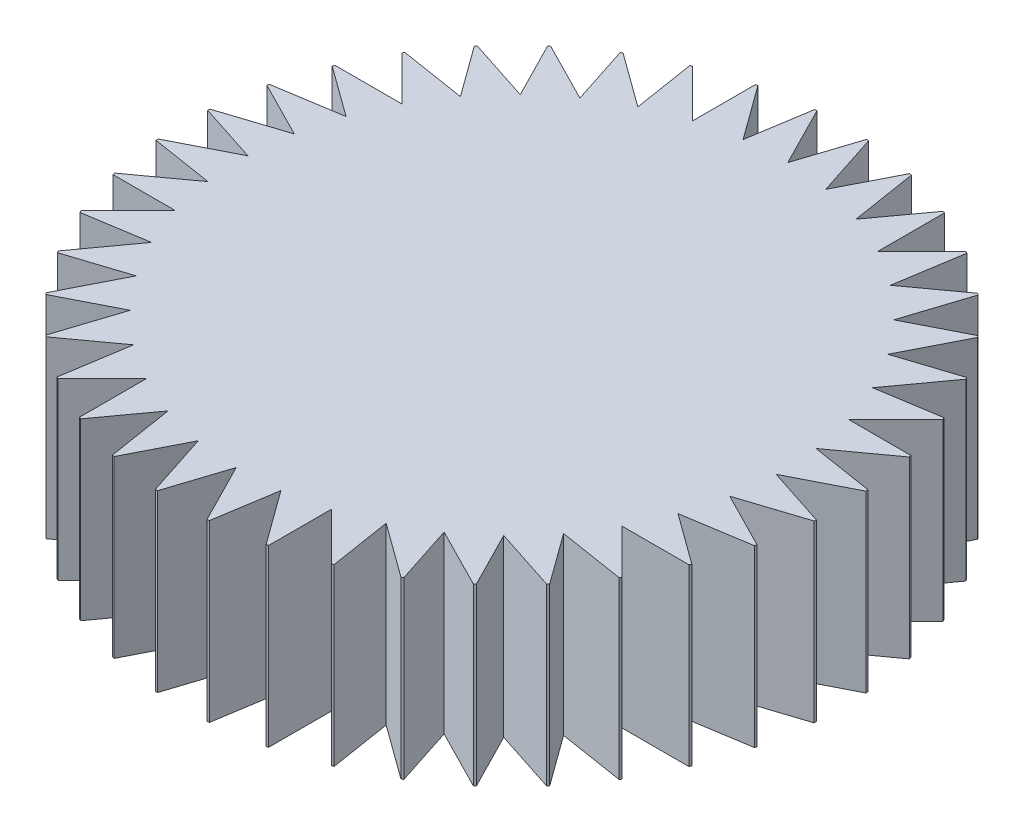
from build123d import *

# Parameters (mm, degrees)
Y_KSEKLIK_EKSTR_ZYON1_DEPTH = 3


with BuildPart() as part:
    # Çizim1 → Yükseklik-Ekstrüzyon1 (new body)
    with BuildSketch(Plane(origin=(0, 0, 0), x_dir=(1, 0, 0), z_dir=(0, 1, 0))):
        with BuildLine():
            Line((-1.336008246, 4.436405178), (-2.146846221, 5.247243153))
            ThreePointArc((-2.146846221, 5.247243153), (-2.164173955, 5.240120274), (-2.181478058, 5.232940176))
            Line((-2.181478058, 5.232940176), (-2.013566438, 4.172787933))
            Line((-2.013566438, 4.172787933), (-2.941264657, 4.846800142))
            ThreePointArc((-2.941264657, 4.846800142), (-2.957264794, 4.837054303), (-2.97323264, 4.827255646))
            Line((-2.97323264, 4.827255646), (-2.641543942, 3.806422801))
            Line((-2.641543942, 3.806422801), (-3.663259395, 4.327012826))
            ThreePointArc((-3.663259395, 4.327012826), (-3.67753796, 4.314884002), (-3.691776367, 4.302708061))
            Line((-3.691776367, 4.302708061), (-3.204477867, 3.346330906))
            Line((-3.204477867, 3.346330906), (-4.29505253, 3.700680094))
            ThreePointArc((-4.29505253, 3.700680094), (-4.307257936, 3.686466936), (-4.319416307, 3.672213524))
            Line((-4.319416307, 3.672213524), (-3.688506912, 2.803841239))
            Line((-3.688506912, 2.803841239), (-4.821087217, 2.983224337))
            ThreePointArc((-4.821087217, 2.983224337), (-4.830918926, 2.96727682), (-4.840697883, 2.951296902))
            Line((-4.840697883, 2.951296902), (-4.081712675, 2.192311695))
            Line((-4.081712675, 2.192311695), (-5.228410736, 2.192311695))
            ThreePointArc((-5.228410736, 2.192311695), (-5.23562666, 2.175022501), (-5.242785411, 2.157709556))
            Line((-5.242785411, 2.157709556), (-4.374413126, 1.526800161))
            Line((-4.374413126, 1.526800161), (-5.506993431, 1.347417063))
            ThreePointArc((-5.506993431, 1.347417063), (-5.511415889, 1.329211909), (-5.515778163, 1.31099224))
            Line((-5.515778163, 1.31099224), (-4.559401008, 0.82369374))
            Line((-4.559401008, 0.82369374), (-5.649975671, 0.469344552))
            ThreePointArc((-5.649975671, 0.469344552), (-5.651495767, 0.450671709), (-5.652954151, 0.431993944))
            Line((-5.652954151, 0.431993944), (-4.632121306, 0.100305246))
            Line((-4.632121306, 0.100305246), (-5.653836759, -0.42028478))
            ThreePointArc((-5.653836759, -0.42028478), (-5.652417064, -0.438965525), (-5.650935646, -0.457641477))
            Line((-5.650935646, -0.457641477), (-4.590783403, -0.625553097))
            Line((-4.590783403, -0.625553097), (-5.518481622, -1.299565306))
            ThreePointArc((-5.518481622, -1.299565306), (-5.514157093, -1.317793971), (-5.509772351, -1.336008246))
            Line((-5.509772351, -1.336008246), (-4.436405178, -1.336008246))
            Line((-4.436405178, -1.336008246), (-5.247243153, -2.146846221))
            ThreePointArc((-5.247243153, -2.146846221), (-5.240120274, -2.164173955), (-5.232940176, -2.181478058))
            Line((-5.232940176, -2.181478058), (-4.172787933, -2.013566438))
            Line((-4.172787933, -2.013566438), (-4.846800142, -2.941264657))
            ThreePointArc((-4.846800142, -2.941264657), (-4.837054303, -2.957264794), (-4.827255646, -2.97323264))
            Line((-4.827255646, -2.97323264), (-3.806422801, -2.641543942))
            Line((-3.806422801, -2.641543942), (-4.327012826, -3.663259395))
            ThreePointArc((-4.327012826, -3.663259395), (-4.314884002, -3.67753796), (-4.302708061, -3.691776367))
            Line((-4.302708061, -3.691776367), (-3.346330906, -3.204477867))
            Line((-3.346330906, -3.204477867), (-3.700680094, -4.29505253))
            ThreePointArc((-3.700680094, -4.29505253), (-3.686466936, -4.307257936), (-3.672213524, -4.319416307))
            Line((-3.672213524, -4.319416307), (-2.803841239, -3.688506912))
            Line((-2.803841239, -3.688506912), (-2.983224337, -4.821087217))
            ThreePointArc((-2.983224337, -4.821087217), (-2.96727682, -4.830918926), (-2.951296902, -4.840697883))
            Line((-2.951296902, -4.840697883), (-2.192311695, -4.081712675))
            Line((-2.192311695, -4.081712675), (-2.192311695, -5.228410736))
            ThreePointArc((-2.192311695, -5.228410736), (-2.175022501, -5.23562666), (-2.157709556, -5.242785411))
            Line((-2.157709556, -5.242785411), (-1.526800161, -4.374413126))
            Line((-1.526800161, -4.374413126), (-1.347417063, -5.506993431))
            ThreePointArc((-1.347417063, -5.506993431), (-1.329211909, -5.511415889), (-1.31099224, -5.515778163))
            Line((-1.31099224, -5.515778163), (-0.82369374, -4.559401008))
            Line((-0.82369374, -4.559401008), (-0.469344552, -5.649975671))
            ThreePointArc((-0.469344552, -5.649975671), (-0.450671709, -5.651495767), (-0.431993944, -5.652954151))
            Line((-0.431993944, -5.652954151), (-0.100305246, -4.632121306))
            Line((-0.100305246, -4.632121306), (0.42028478, -5.653836759))
            ThreePointArc((0.42028478, -5.653836759), (0.438965525, -5.652417064), (0.457641477, -5.650935646))
            Line((0.457641477, -5.650935646), (0.625553097, -4.590783403))
            Line((0.625553097, -4.590783403), (1.299565306, -5.518481622))
            ThreePointArc((1.299565306, -5.518481622), (1.317793971, -5.514157093), (1.336008246, -5.509772351))
            Line((1.336008246, -5.509772351), (1.336008246, -4.436405178))
            Line((1.336008246, -4.436405178), (2.146846221, -5.247243153))
            ThreePointArc((2.146846221, -5.247243153), (2.164173955, -5.240120274), (2.181478058, -5.232940176))
            Line((2.181478058, -5.232940176), (2.013566438, -4.172787933))
            Line((2.013566438, -4.172787933), (2.941264657, -4.846800142))
            ThreePointArc((2.941264657, -4.846800142), (2.957264794, -4.837054303), (2.97323264, -4.827255646))
            Line((2.97323264, -4.827255646), (2.641543942, -3.806422801))
            Line((2.641543942, -3.806422801), (3.663259395, -4.327012826))
            ThreePointArc((3.663259395, -4.327012826), (3.67753796, -4.314884002), (3.691776367, -4.302708061))
            Line((3.691776367, -4.302708061), (3.204477867, -3.346330906))
            Line((3.204477867, -3.346330906), (4.29505253, -3.700680094))
            ThreePointArc((4.29505253, -3.700680094), (4.307257936, -3.686466936), (4.319416307, -3.672213524))
            Line((4.319416307, -3.672213524), (3.688506912, -2.803841239))
            Line((3.688506912, -2.803841239), (4.821087217, -2.983224337))
            ThreePointArc((4.821087217, -2.983224337), (4.830918926, -2.96727682), (4.840697883, -2.951296902))
            Line((4.840697883, -2.951296902), (4.081712675, -2.192311695))
            Line((4.081712675, -2.192311695), (5.228410736, -2.192311695))
            ThreePointArc((5.228410736, -2.192311695), (5.23562666, -2.175022501), (5.242785411, -2.157709556))
            Line((5.242785411, -2.157709556), (4.374413126, -1.526800161))
            Line((4.374413126, -1.526800161), (5.506993431, -1.347417063))
            ThreePointArc((5.506993431, -1.347417063), (5.511415889, -1.329211909), (5.515778163, -1.31099224))
            Line((5.515778163, -1.31099224), (4.559401008, -0.82369374))
            Line((4.559401008, -0.82369374), (5.649975671, -0.469344552))
            ThreePointArc((5.649975671, -0.469344552), (5.651495767, -0.450671709), (5.652954151, -0.431993944))
            Line((5.652954151, -0.431993944), (4.632121306, -0.100305246))
            Line((4.632121306, -0.100305246), (5.653836759, 0.42028478))
            ThreePointArc((5.653836759, 0.42028478), (5.652417064, 0.438965525), (5.650935646, 0.457641477))
            Line((5.650935646, 0.457641477), (4.590783403, 0.625553097))
            Line((4.590783403, 0.625553097), (5.518481622, 1.299565306))
            ThreePointArc((5.518481622, 1.299565306), (5.514157093, 1.317793971), (5.509772351, 1.336008246))
            Line((5.509772351, 1.336008246), (4.436405178, 1.336008246))
            Line((4.436405178, 1.336008246), (5.247243153, 2.146846221))
            ThreePointArc((5.247243153, 2.146846221), (5.240120274, 2.164173955), (5.232940176, 2.181478058))
            Line((5.232940176, 2.181478058), (4.172787933, 2.013566438))
            Line((4.172787933, 2.013566438), (4.846800142, 2.941264657))
            ThreePointArc((4.846800142, 2.941264657), (4.837054303, 2.957264794), (4.827255646, 2.97323264))
            Line((4.827255646, 2.97323264), (3.806422801, 2.641543942))
            Line((3.806422801, 2.641543942), (4.327012826, 3.663259395))
            ThreePointArc((4.327012826, 3.663259395), (4.314884002, 3.67753796), (4.302708061, 3.691776367))
            Line((4.302708061, 3.691776367), (3.346330906, 3.204477867))
            Line((3.346330906, 3.204477867), (3.700680094, 4.29505253))
            ThreePointArc((3.700680094, 4.29505253), (3.686466936, 4.307257936), (3.672213524, 4.319416307))
            Line((3.672213524, 4.319416307), (2.803841239, 3.688506912))
            Line((2.803841239, 3.688506912), (2.983224337, 4.821087217))
            ThreePointArc((2.983224337, 4.821087217), (2.96727682, 4.830918926), (2.951296902, 4.840697883))
            Line((2.951296902, 4.840697883), (2.192311695, 4.081712675))
            Line((2.192311695, 4.081712675), (2.192311695, 5.228410736))
            ThreePointArc((2.192311695, 5.228410736), (2.175022501, 5.23562666), (2.157709556, 5.242785411))
            Line((2.157709556, 5.242785411), (1.526800161, 4.374413126))
            Line((1.526800161, 4.374413126), (1.347417063, 5.506993431))
            ThreePointArc((1.347417063, 5.506993431), (1.329211909, 5.511415889), (1.31099224, 5.515778163))
            Line((1.31099224, 5.515778163), (0.82369374, 4.559401008))
            Line((0.82369374, 4.559401008), (0.469344552, 5.649975671))
            ThreePointArc((0.469344552, 5.649975671), (0.450671709, 5.651495767), (0.431993944, 5.652954151))
            Line((0.431993944, 5.652954151), (0.100305246, 4.632121306))
            Line((0.100305246, 4.632121306), (-0.42028478, 5.653836759))
            ThreePointArc((-0.42028478, 5.653836759), (-0.438965525, 5.652417064), (-0.457641477, 5.650935646))
            Line((-0.457641477, 5.650935646), (-0.625553097, 4.590783403))
            Line((-0.625553097, 4.590783403), (-1.299565306, 5.518481622))
            ThreePointArc((-1.299565306, 5.518481622), (-1.317793971, 5.514157093), (-1.336008246, 5.509772351))
            Line((-1.336008246, 5.509772351), (-1.336008246, 4.436405178))
        make_face()
    extrude(amount=Y_KSEKLIK_EKSTR_ZYON1_DEPTH)


solid = part.part
